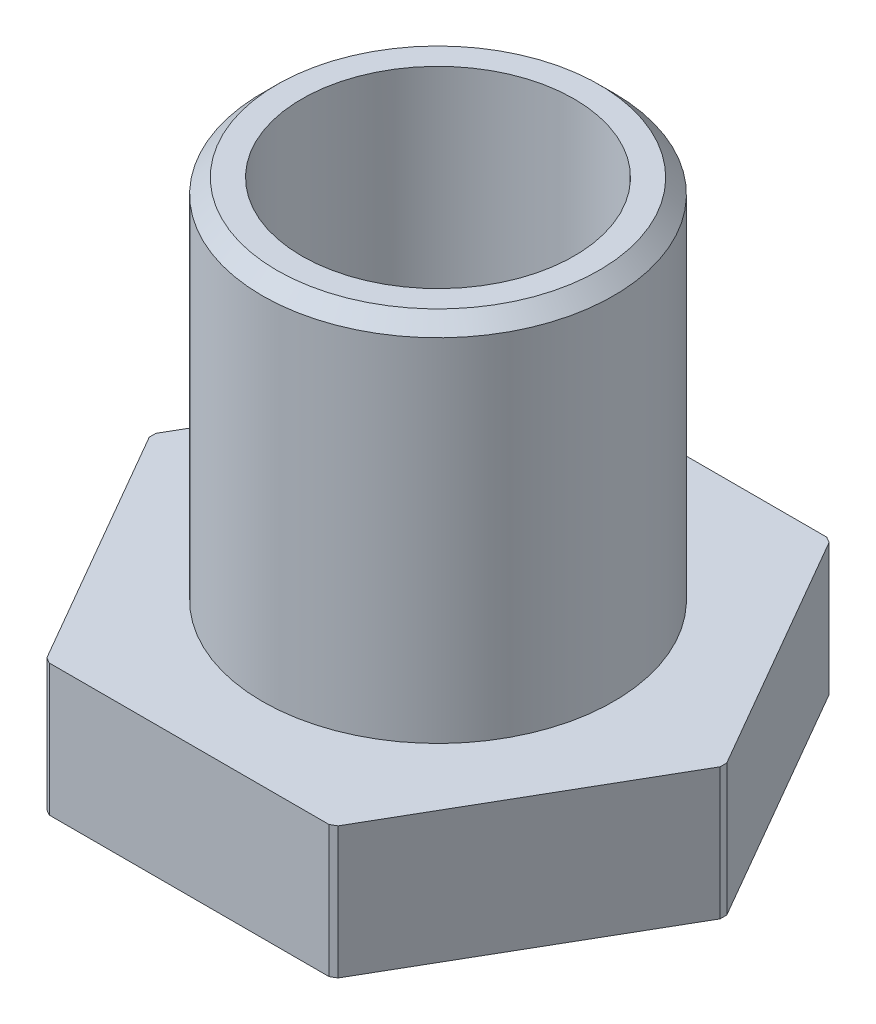
from build123d import *

# Parameters (mm, degrees)
SKETCH_1_R          = 4.65
EXTRUDE_1_DEPTH     = 17
SKETCH_2_R          = 6
CUT_EXTRUDE_1_DEPTH = 12.5
SKETCH_3_R          = 6.75
SKETCH_3_R_2        = 4.65
CUT_EXTRUDE_2_DEPTH = 2.2
CHAMFER_1_SIZE      = 0.5
CUT_EXTRUDE_3_DEPTH = 18


with BuildPart() as part:
    # Эскиз1 → Бобышка-Вытянуть1 (new body)
    with BuildSketch(Plane(origin=(0, 0, 0), x_dir=(1, 0, 0), z_dir=(0, 1, 0))):
        Polygon((9.814954576, 0), (4.907477288, 8.5), (-4.907477288, 8.5), (-9.814954576, 0), (-4.907477288, -8.5), (4.907477288, -8.5), align=None)
        Circle(SKETCH_1_R, mode=Mode.SUBTRACT)
    extrude(amount=EXTRUDE_1_DEPTH)

    # Эскиз2 → Вырез-Вытянуть1 (cut)
    with BuildSketch(Plane(origin=(0, 17, 0), x_dir=(1, 0, 0), z_dir=(0, 1, 0))):
        Polygon((-4.907477288, -8.5), (4.907477288, -8.5), (9.814954576, 0), (4.907477288, 8.5), (-4.907477288, 8.5), (-9.814954576, 0), align=None)
        Circle(SKETCH_2_R, mode=Mode.SUBTRACT)
    extrude(amount=-CUT_EXTRUDE_1_DEPTH, mode=Mode.SUBTRACT)

    # Эскиз3 → Вырез-Вытянуть2 (cut)
    with BuildSketch(Plane.XZ):
        Circle(SKETCH_3_R)
        Circle(SKETCH_3_R_2, mode=Mode.SUBTRACT)
    extrude(amount=-CUT_EXTRUDE_2_DEPTH, mode=Mode.SUBTRACT)

    # Фаска1
    chamfer_1_edges = [part.edges().sort_by_distance(p)[0] for p in [
        (-6, 17, 0),
    ]]
    chamfer(chamfer_1_edges, length=CHAMFER_1_SIZE)

    # Эскиз4 → Вырез-Вытянуть3 (cut, through all)
    with BuildSketch(Plane.XZ):
        with BuildLine():
            ThreePointArc((-9.749337579, -0.113651973), (-9.75, 0), (-9.749337579, 0.113651973))
            Line((-9.749337579, 0.113651973), (-9.814954576, 0))
            Line((-9.814954576, 0), (-9.749337579, -0.113651973))
        make_face()
        with BuildLine():
            ThreePointArc((-4.973094285, 8.386348027), (-4.875, 8.443747687), (-4.776243294, 8.5))
            Line((-4.776243294, 8.5), (-4.907477288, 8.5))
            Line((-4.907477288, 8.5), (-4.973094285, 8.386348027))
        make_face()
        with BuildLine():
            ThreePointArc((4.776243294, 8.5), (4.875, 8.443747687), (4.973094285, 8.386348027))
            Line((4.973094285, 8.386348027), (4.907477288, 8.5))
            Line((4.907477288, 8.5), (4.776243294, 8.5))
        make_face()
        with BuildLine():
            ThreePointArc((9.749337579, 0.113651973), (9.749834393, 0.056826952), (9.75, 0))
            ThreePointArc((9.75, 0), (9.749834393, -0.056826952), (9.749337579, -0.113651973))
            Line((9.749337579, -0.113651973), (9.814954576, 0))
            Line((9.814954576, 0), (9.749337579, 0.113651973))
        make_face()
        with BuildLine():
            Line((4.907477288, -8.5), (4.973094285, -8.386348027))
            ThreePointArc((4.973094285, -8.386348027), (4.875, -8.443747687), (4.776243294, -8.5))
            Line((4.776243294, -8.5), (4.907477288, -8.5))
        make_face()
        with BuildLine():
            Line((-4.907477288, -8.5), (-4.776243294, -8.5))
            ThreePointArc((-4.776243294, -8.5), (-4.875, -8.443747687), (-4.973094285, -8.386348027))
            Line((-4.973094285, -8.386348027), (-4.907477288, -8.5))
        make_face()
    extrude(amount=-CUT_EXTRUDE_3_DEPTH, mode=Mode.SUBTRACT)


solid = part.part
